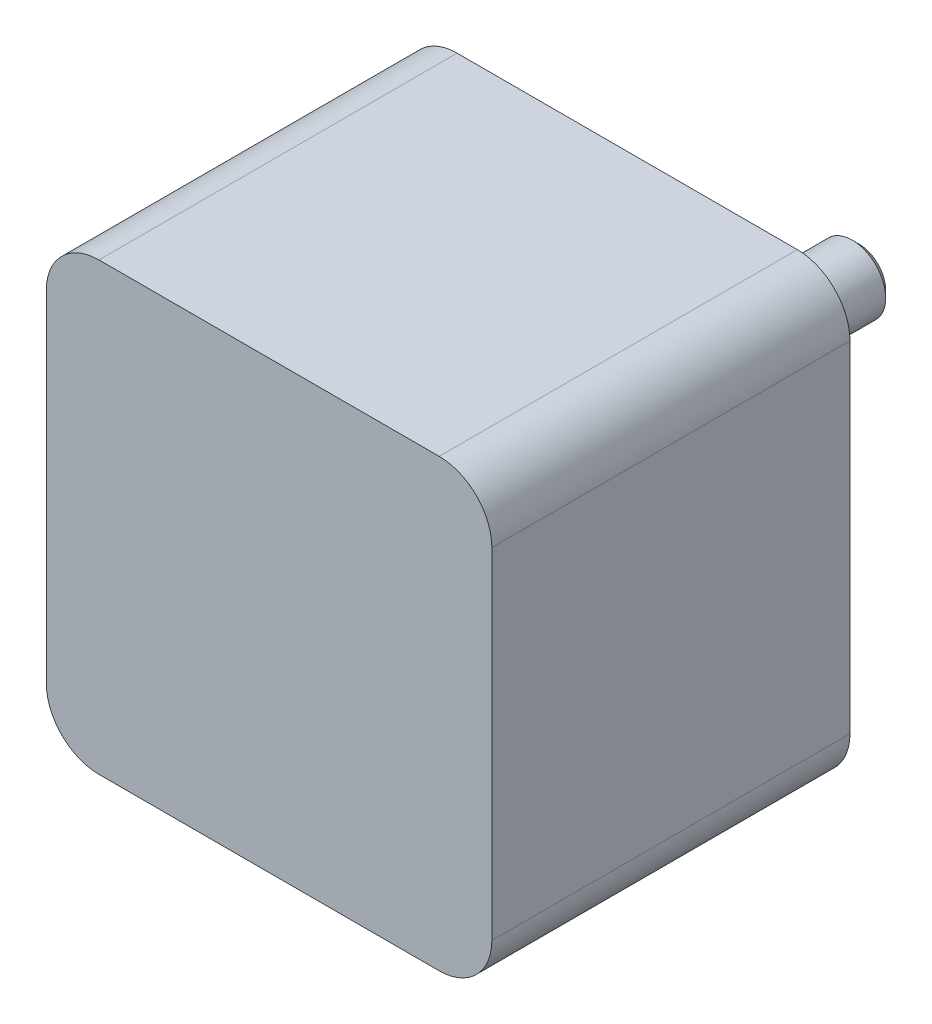
from build123d import *

# Parameters (mm, degrees)
SKETCH1_R           = 1.5875
BOSS_EXTRUDE1_DEPTH = 32
BOSS_EXTRUDE2_DEPTH = 2
SKETCH3_R           = 11
BOSS_EXTRUDE3_DEPTH = 2
SKETCH4_R           = 3.175
BOSS_EXTRUDE4_DEPTH = 20
CHAMFER1_SIZE       = 0.635


with BuildPart() as part:
    # Sketch1 → Boss-Extrude1 (new body)
    with BuildSketch(Plane.XY):
        with BuildLine():
            Line((-16.15, -21.15), (16.15, -21.15))
            ThreePointArc((16.15, -21.15), (19.685533906, -19.685533906), (21.15, -16.15))
            Line((21.15, -16.15), (21.15, 16.15))
            ThreePointArc((21.15, 16.15), (19.685533906, 19.685533906), (16.15, 21.15))
            Line((16.15, 21.15), (-16.15, 21.15))
            ThreePointArc((-16.15, 21.15), (-19.685533906, 19.685533906), (-21.15, 16.15))
            Line((-21.15, 16.15), (-21.15, -16.15))
            ThreePointArc((-21.15, -16.15), (-19.685533906, -19.685533906), (-16.15, -21.15))
        make_face()
        with Locations((15.5, 15.5)):
            Circle(SKETCH1_R, mode=Mode.SUBTRACT)
        with Locations((-15.5, 15.5)):
            Circle(SKETCH1_R, mode=Mode.SUBTRACT)
        with Locations((15.5, -15.5)):
            Circle(SKETCH1_R, mode=Mode.SUBTRACT)
        with Locations((-15.5, -15.5)):
            Circle(SKETCH1_R, mode=Mode.SUBTRACT)
    extrude(amount=BOSS_EXTRUDE1_DEPTH)

    # Sketch2 → Boss-Extrude2 (add)
    with BuildSketch(Plane.XY.offset(32)):
        with BuildLine():
            Line((-16.15, -21.15), (16.15, -21.15))
            ThreePointArc((16.15, -21.15), (19.685533906, -19.685533906), (21.15, -16.15))
            Line((21.15, -16.15), (21.15, 16.15))
            ThreePointArc((21.15, 16.15), (19.685533906, 19.685533906), (16.15, 21.15))
            Line((16.15, 21.15), (-16.15, 21.15))
            ThreePointArc((-16.15, 21.15), (-19.685533906, 19.685533906), (-21.15, 16.15))
            Line((-21.15, 16.15), (-21.15, -16.15))
            ThreePointArc((-21.15, -16.15), (-19.685533906, -19.685533906), (-16.15, -21.15))
        make_face()
    extrude(amount=BOSS_EXTRUDE2_DEPTH)

    # Sketch3 → Boss-Extrude3 (add)
    with BuildSketch(Plane(origin=(0, 0, 0), x_dir=(-1, 0, 0), z_dir=(0, 0, -1))):
        Circle(SKETCH3_R)
    extrude(amount=BOSS_EXTRUDE3_DEPTH)

    # Sketch4 → Boss-Extrude4 (add)
    with BuildSketch(Plane(origin=(0, 0, -2), x_dir=(-1, 0, 0), z_dir=(0, 0, -1))):
        Circle(SKETCH4_R)
    extrude(amount=BOSS_EXTRUDE4_DEPTH)

    # Chamfer1
    chamfer1_edges = [part.edges().sort_by_distance(p)[0] for p in [
        (3.175, 0, -22),
    ]]
    chamfer(chamfer1_edges, length=CHAMFER1_SIZE)


solid = part.part
